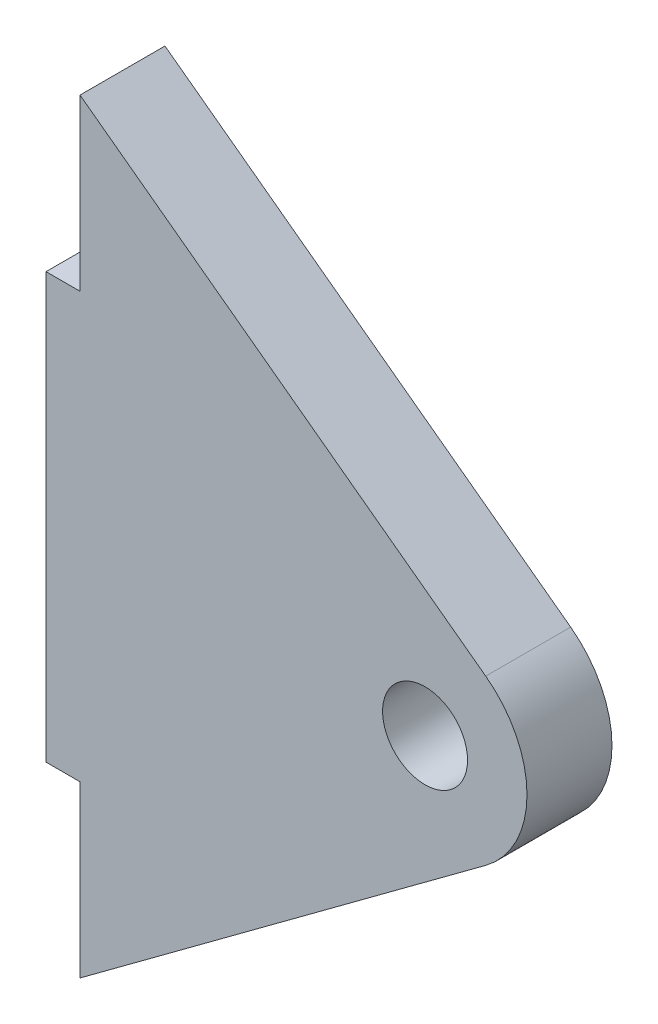
from build123d import *

# Parameters (mm, degrees)
SZKIC1_R                    = 2.5
SZKIC1_W                    = 2
SZKIC1_H                    = 25
DODANIE_WYCI_GNI_CIE1_DEPTH = 5


with BuildPart() as part:
    # Szkic1 → Dodanie-wyciągnięcie1 (new body)
    with BuildSketch(Plane.XY):
        with BuildLine():
            ThreePointArc((214.351594971, 216.879691308), (216.781303051, 212.057553235), (214.351594971, 207.235415161))
            Line((214.351594971, 207.235415161), (190.475370577, 189.557553235))
            Line((190.475370577, 189.557553235), (190.475370577, 199.557553235))
            Line((190.475370577, 199.557553235), (190.475370577, 224.557553235))
            Line((190.475370577, 224.557553235), (190.475370577, 234.557553235))
            Line((190.475370577, 234.557553235), (214.351594971, 216.879691308))
        make_face()
        with Locations((210.781303051, 212.057553235)):
            Circle(SZKIC1_R, mode=Mode.SUBTRACT)
        with Locations((189.475370577, 212.057553235)):
            Rectangle(SZKIC1_W, SZKIC1_H)
    extrude(amount=DODANIE_WYCI_GNI_CIE1_DEPTH)


solid = part.part
